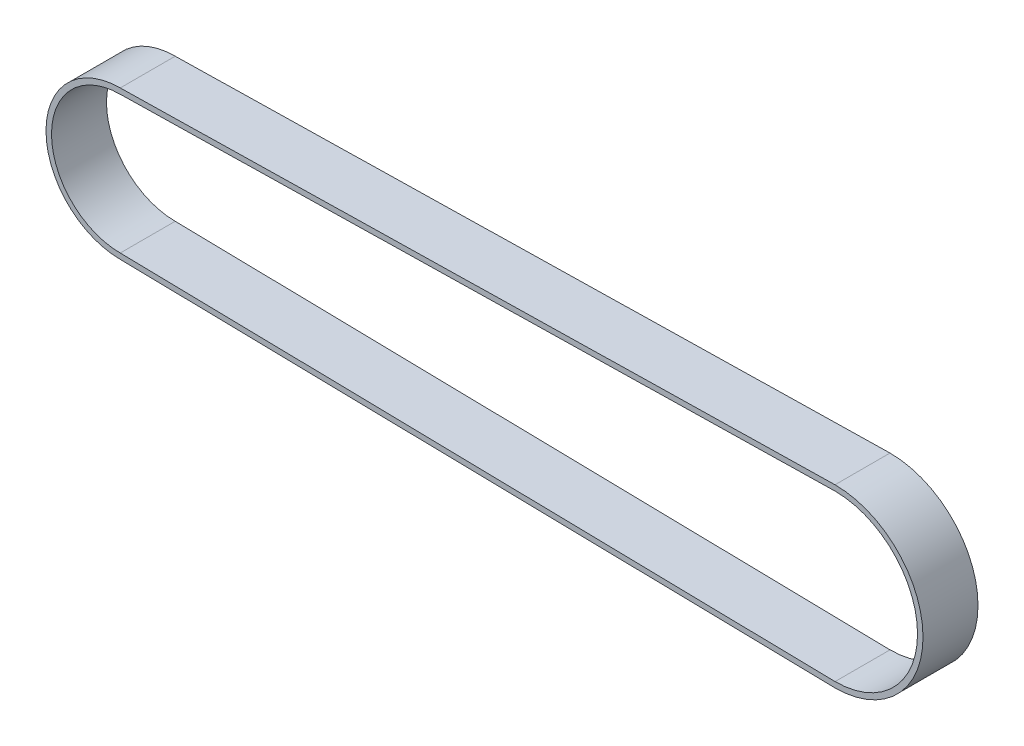
from build123d import *

# Parameters (mm, degrees)
BOSS_EXTRU_1_DEPTH = 10


with BuildPart() as part:
    # Esquisse1 → Boss.-Extru.1 (new body)
    with BuildSketch(Plane.XY):
        with BuildLine():
            Line((-63.375139476, 11.236602162), (66.624860524, 13.736602162))
            ThreePointArc((66.624860524, 13.736602162), (82.624860524, -2.263397838), (66.624860524, -18.263397838))
            Line((66.624860524, -18.263397838), (-63.375139476, -15.763397838))
            ThreePointArc((-63.375139476, -15.763397838), (-76.875139476, -2.263397838), (-63.375139476, 11.236602162))
        make_face()
        with BuildLine():
            Line((-63.375139476, 10.236602162), (66.624860524, 12.736602162))
            ThreePointArc((66.624860524, 12.736602162), (81.624860524, -2.263397838), (66.624860524, -17.263397838))
            Line((66.624860524, -17.263397838), (-63.375139476, -14.763397838))
            ThreePointArc((-63.375139476, -14.763397838), (-75.875139476, -2.263397838), (-63.375139476, 10.236602162))
        make_face(mode=Mode.SUBTRACT)
    extrude(amount=BOSS_EXTRU_1_DEPTH)


solid = part.part
